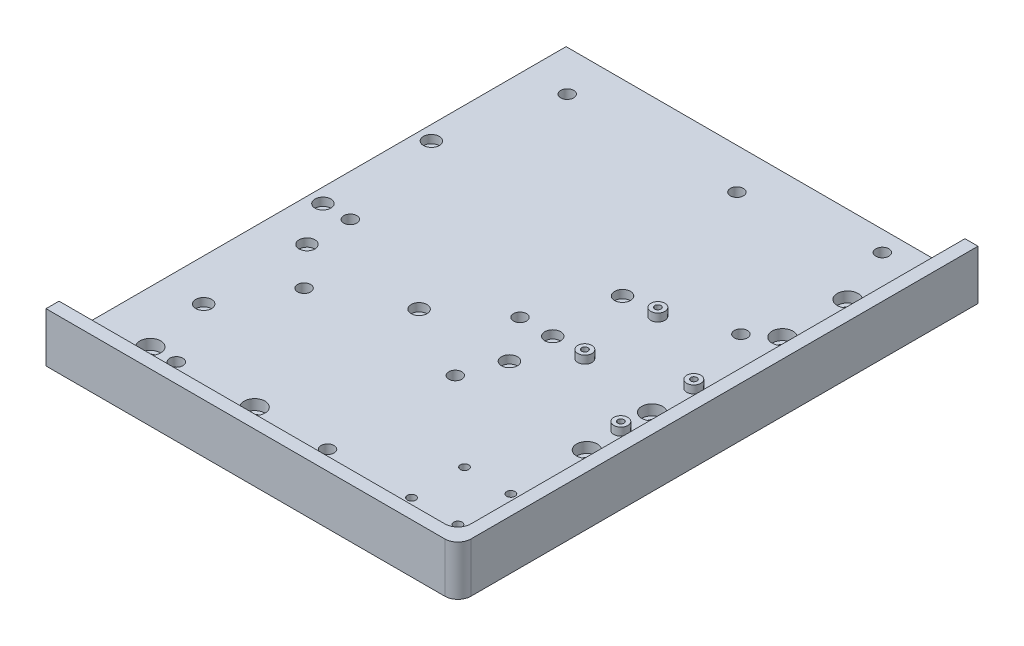
from build123d import *

# Parameters (mm, degrees)
SKETCH1_W                      = 158
SKETCH1_H                      = 199.5
BOSS_EXTRUDE1_DEPTH            = 6.35
BOSS_EXTRUDE2_DEPTH            = 12.7
CBORE_FOR_M4_SHCS1_D           = 4.5
CBORE_FOR_M4_SHCS1_DEPTH       = 6.35
CBORE_FOR_M4_SHCS1_CBORE_D     = 8
CBORE_FOR_M4_SHCS1_CBORE_DEPTH = 4
FILLET2_R                      = 5
FILLET3_R                      = 5
SKETCH8_R                      = 2.5
ESTOP_DEPTH                    = 7.35
SKETCH9_R                      = 2.5
NUCLEOANDPI_DEPTH              = 7.35
SKETCH10_R                     = 2.7
SKETCH10_R_2                   = 1.2
BUCKS_EXTRUDE_DEPTH            = 3
SKETCH11_R                     = 1.6
BUCKS_CUT_DEPTH                = 6.35
BUCK_2_COUNT                   = 2
BUCK_2_PITCH                   = 28
SKETCH12_R                     = 2.5
PI_2_DEPTH                     = 7.35
SKETCH13_R                     = 1.6
IMU_DEPTH                      = 7.35
SKETCH15_R                     = 3.05
MAGNETS_DEPTH                  = 3.1


with BuildPart() as part:
    # Sketch1 → Boss-Extrude1 (new body)
    with BuildSketch(Plane(origin=(0, 0, 0), x_dir=(1, 0, 0), z_dir=(0, 1, 0))):
        with Locations((79, -99.75)):
            Rectangle(SKETCH1_W, SKETCH1_H)
    extrude(amount=BOSS_EXTRUDE1_DEPTH)

    # Sketch3 → Boss-Extrude2 (add)
    with BuildSketch(Plane(origin=(0, 6.35, 0), x_dir=(1, 0, 0), z_dir=(0, 1, 0))):
        Polygon((158, -199.5), (158, 0), (153, 0), (153, -194.5), (0, -194.5), (0, -199.5), align=None)
    extrude(amount=BOSS_EXTRUDE2_DEPTH)

    # CBORE for M4 SHCS1
    with Locations(Plane(origin=(0, 6.35, 0), x_dir=(1, 0, 0), z_dir=(0, 1, 0))):
        with Locations((138, -55), (20, -179.5), (60, -179.5), (138, -130), (138, -105), (138, -30)):
            CounterBoreHole(CBORE_FOR_M4_SHCS1_D / 2, CBORE_FOR_M4_SHCS1_CBORE_D / 2, CBORE_FOR_M4_SHCS1_CBORE_DEPTH, depth=CBORE_FOR_M4_SHCS1_DEPTH)

    # Fillet2
    fillet2_edges = [part.edges().sort_by_distance(p)[0] for p in [
        (158, 9.525, 199.5),
    ]]
    fillet(fillet2_edges, radius=FILLET2_R)

    # Fillet3
    fillet3_edges = [part.edges().sort_by_distance(p)[0] for p in [
        (153, 12.7, 194.5),
    ]]
    fillet(fillet3_edges, radius=FILLET3_R)

    # Sketch8 → eStop (cut, through all)
    with BuildSketch(Plane(origin=(0, 6.35, 0), x_dir=(1, 0, 0), z_dir=(0, 1, 0))):
        with Locations((129.05, -62)):
            Circle(SKETCH8_R)
        with Locations((129.05, -7.75)):
            Circle(SKETCH8_R)
    extrude(amount=-ESTOP_DEPTH, mode=Mode.SUBTRACT)

    # Sketch9 → NucleoAndPi (cut, through all)
    with BuildSketch(Plane(origin=(0, 6.35, 0), x_dir=(1, 0, 0), z_dir=(0, 1, 0))):
        with Locations((16, -15.57)):
            Circle(SKETCH9_R)
        with Locations((81.1, -15.57)):
            Circle(SKETCH9_R)
        with Locations((81.1, -98.77)):
            Circle(SKETCH9_R)
        with Locations((16, -98.77)):
            Circle(SKETCH9_R)
    extrude(amount=-NUCLEOANDPI_DEPTH, mode=Mode.SUBTRACT)

    # Sketch10 → Bucks - Extrude (add)
    with BuildSketch(Plane(origin=(0, 6.35, 0), x_dir=(1, 0, 0), z_dir=(0, 1, 0))):
        with Locations((138, -89)):
            Circle(SKETCH10_R)
        with Locations((138, -89)):
            Circle(SKETCH10_R_2, mode=Mode.SUBTRACT)
        with Locations((107.2, -72)):
            Circle(SKETCH10_R)
        with Locations((107.2, -72)):
            Circle(SKETCH10_R_2, mode=Mode.SUBTRACT)
    bucks_extrude = extrude(amount=BUCKS_EXTRUDE_DEPTH)

    # Sketch11 → Bucks - Cut (cut)
    with BuildSketch(Plane(origin=(0, 6.35, 0), x_dir=(1, 0, 0), z_dir=(0, 1, 0))):
        with Locations((138, -89)):
            Circle(SKETCH11_R)
        with Locations((107.2, -72)):
            Circle(SKETCH11_R)
    bucks_cut = extrude(amount=-BUCKS_CUT_DEPTH, mode=Mode.SUBTRACT)

    # Buck 2: Bucks - Extrude, Bucks - Cut ×2
    with Locations(*[(0, 0, i * BUCK_2_PITCH) for i in range(1, BUCK_2_COUNT)]):
        add(bucks_extrude)
        add(bucks_cut, mode=Mode.SUBTRACT)

    # Sketch12 → Pi 2 (cut, through all)
    with BuildSketch(Plane(origin=(0, 6.35, 0), x_dir=(1, 0, 0), z_dir=(0, 1, 0))):
        with Locations((30, -130.5)):
            Circle(SKETCH12_R)
        with Locations((88, -130.5)):
            Circle(SKETCH12_R)
        with Locations((88, -179.5)):
            Circle(SKETCH12_R)
        with Locations((30, -179.5)):
            Circle(SKETCH12_R)
    extrude(amount=-PI_2_DEPTH, mode=Mode.SUBTRACT)

    # Sketch13 → IMU (cut, through all)
    with BuildSketch(Plane(origin=(0, 6.35, 0), x_dir=(1, 0, 0), z_dir=(0, 1, 0))):
        with Locations((120.22, -159.18)):
            Circle(SKETCH13_R)
        with Locations((120.22, -179.5)):
            Circle(SKETCH13_R)
        with Locations((138, -159.18)):
            Circle(SKETCH13_R)
        with Locations((138, -179.5)):
            Circle(SKETCH13_R)
    extrude(amount=-IMU_DEPTH, mode=Mode.SUBTRACT)

    # Sketch15 → MAGNETS (cut)
    with BuildSketch(Plane(origin=(0, 6.35, 0), x_dir=(1, 0, 0), z_dir=(0, 1, 0))):
        with Locations((5.5, -57.17)):
            Circle(SKETCH15_R)
        with Locations((5.5, -98.77)):
            Circle(SKETCH15_R)
        with Locations((16, -115.385)):
            Circle(SKETCH15_R)
        with Locations((59, -115.385)):
            Circle(SKETCH15_R)
        with Locations((93.65, -98.77)):
            Circle(SKETCH15_R)
        with Locations((93.65, -115.385)):
            Circle(SKETCH15_R)
        with Locations((93.65, -72)):
            Circle(SKETCH15_R)
        with Locations((16, -155)):
            Circle(SKETCH15_R)
    extrude(amount=-MAGNETS_DEPTH, mode=Mode.SUBTRACT)


solid = part.part
